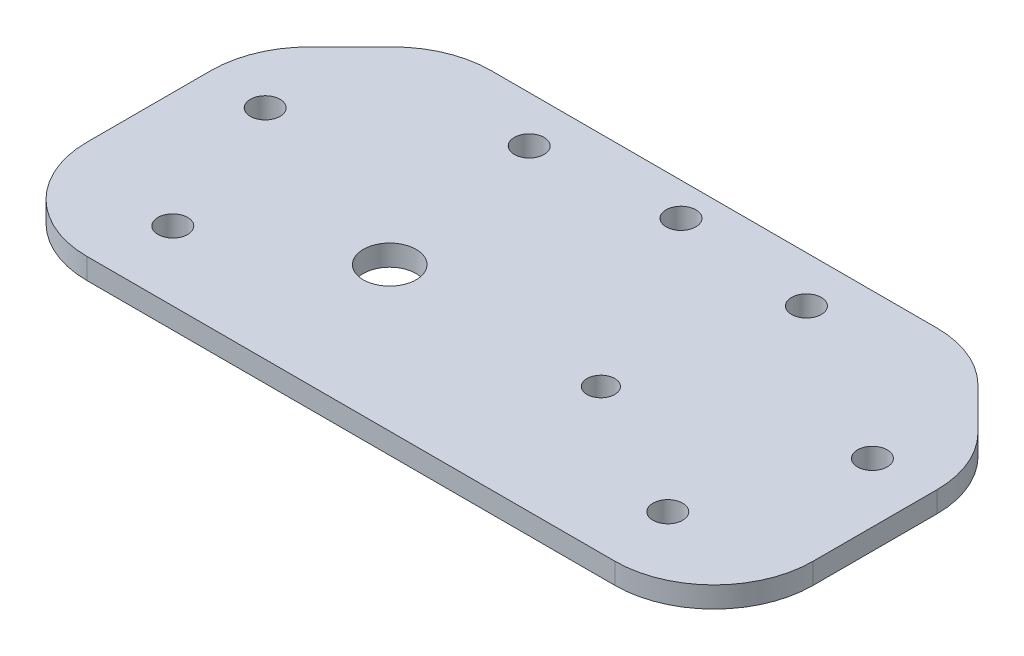
from build123d import *

# Parameters (mm, degrees)
SKETCH2_W                = 110
SKETCH2_H                = 55
BOSS_EXTRUDE1_DEPTH      = 1.5875
M4_CLEARANCE_HOLE1_D     = 4.5
M4_CLEARANCE_HOLE2_D     = 4.5
M4_CLEARANCE_HOLE2_DEPTH = 10.1
M4_CLEARANCE_HOLE2_TIP   = 1.351936393
M4_CLEARANCE_HOLE3_D     = 4.5
CHAMFER1_SIZE            = 15
FILLET1_R                = 15
SKETCH9_R                = 4
CUT_EXTRUDE1_DEPTH       = 4.175
M5X0_8_TAPPED_HOLE1_D    = 4.2


with BuildPart() as part:
    # Sketch2 → Boss-Extrude1 (new body, symmetric)
    with BuildSketch(Plane(origin=(0, 0, 0), x_dir=(1, 0, 0), z_dir=(0, 1, 0))):
        Rectangle(SKETCH2_W, SKETCH2_H)
    extrude(amount=BOSS_EXTRUDE1_DEPTH, both=True)

    # M4 Clearance Hole1 (through all)
    with Locations(Plane(origin=(0, 1.5875, 0), x_dir=(1, 0, 0), z_dir=(0, 1, 0))):
        with Locations((-37.5, -17), (37.5, -17)):
            Hole(M4_CLEARANCE_HOLE1_D / 2)

    # M4 Clearance Hole2
    with Locations(Plane(origin=(0, 1.5875, 0), x_dir=(1, 0, 0), z_dir=(0, 1, 0))):
        with Locations((0, 22.5)):
            Hole(M4_CLEARANCE_HOLE2_D / 2, depth=M4_CLEARANCE_HOLE2_DEPTH)
            with Locations((0, 0, -(M4_CLEARANCE_HOLE2_DEPTH + M4_CLEARANCE_HOLE2_TIP / 2))):  # 118° drill point
                Cone(0, M4_CLEARANCE_HOLE2_D / 2, M4_CLEARANCE_HOLE2_TIP, mode=Mode.SUBTRACT)

    # M4 Clearance Hole3 (through all)
    with Locations(Plane(origin=(0, 1.5875, 0), x_dir=(1, 0, 0), z_dir=(0, 1, 0))):
        with Locations((-46, 5.5), (46, 5.5), (21, 20.5), (-21, 20.5)):
            Hole(M4_CLEARANCE_HOLE3_D / 2)

    # Chamfer1
    chamfer1_edges = [part.edges().sort_by_distance(p)[0] for p in [
        (-55, 0, -27.5),
        (55, 0, -27.5),
    ]]
    chamfer(chamfer1_edges, length=CHAMFER1_SIZE)

    # Fillet1
    fillet1_edges = [part.edges().sort_by_distance(p)[0] for p in [
        (-55, 0, -12.5),
        (40, 0, -27.5),
        (-40, 0, -27.5),
        (55, 0, -12.5),
        (55, 0, 27.5),
        (-55, 0, 27.5),
    ]]
    fillet(fillet1_edges, radius=FILLET1_R)

    # Sketch9 → Cut-Extrude1 (cut, through all)
    with BuildSketch(Plane(origin=(0, 1.5875, 0), x_dir=(1, 0, 0), z_dir=(0, 1, 0))):
        with Locations((-16, -5.635528726)):
            Circle(SKETCH9_R)
    extrude(amount=-CUT_EXTRUDE1_DEPTH, mode=Mode.SUBTRACT)

    # M5x0.8 Tapped Hole1 (through all)
    with Locations(Plane(origin=(0, 1.5875, 0), x_dir=(1, 0, 0), z_dir=(0, 1, 0))):
        with Locations((16, -5.635528726)):
            Hole(M5X0_8_TAPPED_HOLE1_D / 2)


solid = part.part
